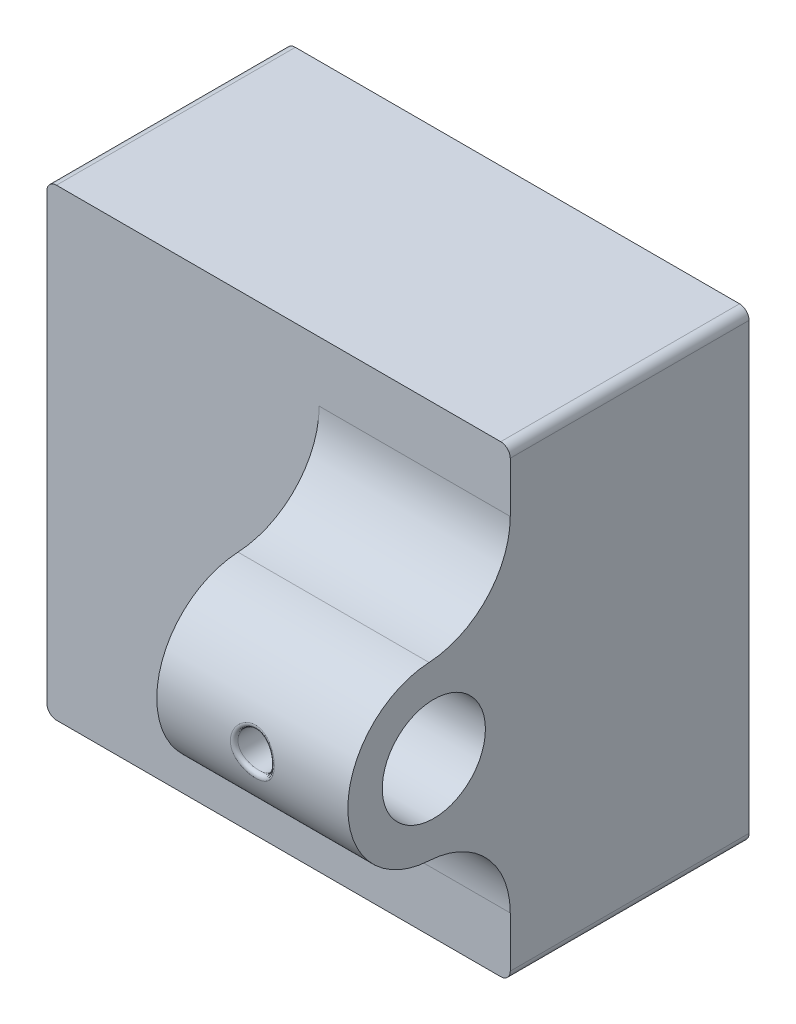
from build123d import *

# Parameters (mm, degrees)
BOSS_EXTRUDE1_DEPTH = 5
SKETCH3_R           = 5.4
BOSS_EXTRUDE2_DEPTH = 10
BOSS_EXTRUDE3_START = -20
BOSS_EXTRUDE3_DEPTH = 20
FILLET1_R           = 2
SKETCH4_R           = 1.9
CUT_EXTRUDE1_DEPTH  = 10
FILLET2_R           = 0.4


with BuildPart() as part:
    # Sketch2 → Boss-Extrude1 (new body)
    with BuildSketch(Plane.XY):
        with BuildLine():
            Line((23.25, 24.25), (-23.25, 24.25))
            ThreePointArc((-23.25, 24.25), (-23.957106781, 23.957106781), (-24.25, 23.25))
            Line((-24.25, 23.25), (-24.25, -23.25))
            ThreePointArc((-24.25, -23.25), (-23.957106781, -23.957106781), (-23.25, -24.25))
            Line((-23.25, -24.25), (23.25, -24.25))
            ThreePointArc((23.25, -24.25), (23.957106781, -23.957106781), (24.25, -23.25))
            Line((24.25, -23.25), (24.25, 23.25))
            ThreePointArc((24.25, 23.25), (23.957106781, 23.957106781), (23.25, 24.25))
        make_face()
    extrude(amount=BOSS_EXTRUDE1_DEPTH)

    # Sketch3 → Boss-Extrude2 (add, symmetric)
    with BuildSketch(Plane(origin=(14.25, 0, 0), x_dir=(0, 0, -1), z_dir=(1, 0, 0))):
        with BuildLine():
            Line((-5, -17.972200756), (-5, 17.972200756))
            ThreePointArc((-5, 17.972200756), (-7.461651585, 11.787542317), (-13.5, 8.986100378))
            ThreePointArc((-13.5, 8.986100378), (-22, 0), (-13.5, -8.986100378))
            ThreePointArc((-13.5, -8.986100378), (-7.461651585, -11.787542317), (-5, -17.972200756))
        make_face()
        with Locations((-13, 0)):
            Circle(SKETCH3_R, mode=Mode.SUBTRACT)
    extrude(amount=BOSS_EXTRUDE2_DEPTH, both=True)

    # Sketch2_3 → Boss-Extrude3 (add)
    with BuildSketch(Plane.XY.offset(BOSS_EXTRUDE3_START)):
        with BuildLine():
            Line((23.25, 24.25), (-23.25, 24.25))
            ThreePointArc((-23.25, 24.25), (-23.957106781, 23.957106781), (-24.25, 23.25))
            Line((-24.25, 23.25), (-24.25, -23.25))
            ThreePointArc((-24.25, -23.25), (-23.957106781, -23.957106781), (-23.25, -24.25))
            Line((-23.25, -24.25), (23.25, -24.25))
            ThreePointArc((23.25, -24.25), (23.957106781, -23.957106781), (24.25, -23.25))
            Line((24.25, -23.25), (24.25, 23.25))
            ThreePointArc((24.25, 23.25), (23.957106781, 23.957106781), (23.25, 24.25))
        make_face()
        with BuildLine():
            Line((20.25, 19.25), (20.25, 4))
            Line((20.25, 4), (14.25, 4))
            Line((14.25, 4), (14.25, -4))
            Line((14.25, -4), (20.25, -4))
            Line((20.25, -4), (20.25, -19.25))
            ThreePointArc((20.25, -19.25), (19.957106781, -19.957106781), (19.25, -20.25))
            Line((19.25, -20.25), (-19.25, -20.25))
            ThreePointArc((-19.25, -20.25), (-19.957106781, -19.957106781), (-20.25, -19.25))
            Line((-20.25, -19.25), (-20.25, 19.25))
            ThreePointArc((-20.25, 19.25), (-19.957106781, 19.957106781), (-19.25, 20.25))
            Line((-19.25, 20.25), (19.25, 20.25))
            ThreePointArc((19.25, 20.25), (19.957106781, 19.957106781), (20.25, 19.25))
        make_face(mode=Mode.SUBTRACT)
    extrude(amount=BOSS_EXTRUDE3_DEPTH)

    # Fillet1
    fillet1_edges = [part.edges().sort_by_distance(p)[0] for p in [
        (14.25, -4, -10),
        (14.25, 4, -10),
    ]]
    fillet(fillet1_edges, radius=FILLET1_R)

    # Sketch4 → Cut-Extrude1 (cut)
    with BuildSketch(Plane.XY.offset(22)):
        with Locations((14.25, 0)):
            Circle(SKETCH4_R)
    extrude(amount=-CUT_EXTRUDE1_DEPTH, mode=Mode.SUBTRACT)

    # Fillet2
    fillet2_edges = [part.edges().sort_by_distance(p)[0] for p in [
        (12.349999989, 0, 21.999999997),
    ]]
    fillet(fillet2_edges, radius=FILLET2_R)


solid = part.part
